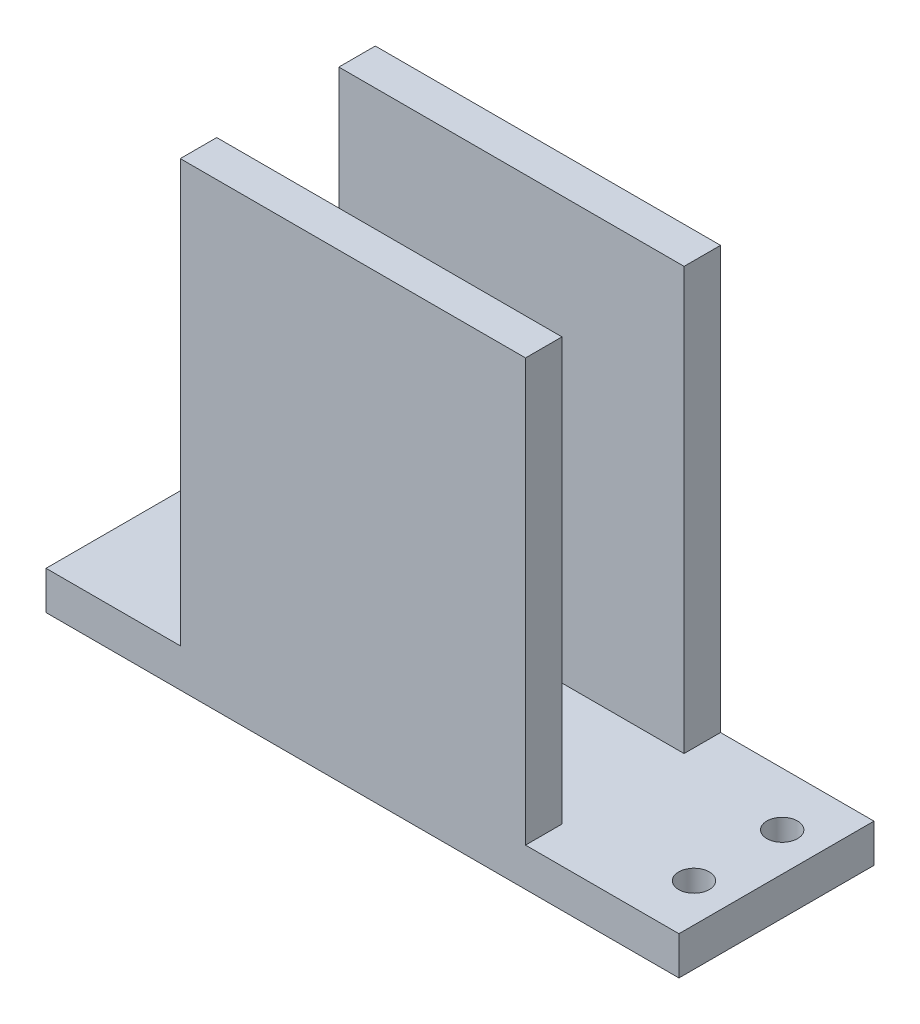
from build123d import *

# Parameters (mm, degrees)
SKETCH1_W           = 165
SKETCH1_H           = 50.84
BOSS_EXTRUDE1_DEPTH = 10
SKETCH2_W           = 90
SKETCH2_H           = 10
BOSS_EXTRUDE2_DEPTH = 110
SKETCH3_R           = 4
CUT_EXTRUDE1_DEPTH  = 30
SKETCH4_W           = 90
SKETCH4_H           = 110
CUT_EXTRUDE2_DEPTH  = 0.5


with BuildPart() as part:
    # Sketch1 → Boss-Extrude1 (new body)
    with BuildSketch(Plane(origin=(0, 0, 0), x_dir=(1, 0, 0), z_dir=(0, 1, 0))):
        with Locations((82.5, 25.42)):
            Rectangle(SKETCH1_W, SKETCH1_H)
    extrude(amount=BOSS_EXTRUDE1_DEPTH)

    # Sketch2 → Boss-Extrude2 (add)
    with BuildSketch(Plane(origin=(0, 10, 0), x_dir=(1, 0, 0), z_dir=(0, 1, 0))):
        with Locations((80, 45.84)):
            Rectangle(SKETCH2_W, SKETCH2_H)
        with Locations((80, 5)):
            Rectangle(SKETCH2_W, SKETCH2_H)
    extrude(amount=BOSS_EXTRUDE2_DEPTH)

    # Sketch3 → Cut-Extrude1 (cut)
    with BuildSketch(Plane(origin=(0, 10, 0), x_dir=(1, 0, 0), z_dir=(0, 1, 0))):
        with Locations((30, 36.92)):
            Circle(SKETCH3_R)
        with Locations((155, 36.92)):
            Circle(SKETCH3_R)
    cut_extrude1 = extrude(amount=-CUT_EXTRUDE1_DEPTH, mode=Mode.SUBTRACT)

    # Mirror1: Cut-Extrude1 across plane
    add(cut_extrude1.mirror(Plane(origin=(0, 0, -25.42), x_dir=(1, 0, 0), z_dir=(0, 0, -1))), mode=Mode.SUBTRACT)

    # Sketch4 → Cut-Extrude2 (cut)
    with BuildSketch(Plane(origin=(0, 0, -10), x_dir=(-1, 0, 0), z_dir=(0, 0, -1))):
        with Locations((-80, 65)):
            Rectangle(SKETCH4_W, SKETCH4_H)
    cut_extrude2 = extrude(amount=-CUT_EXTRUDE2_DEPTH, mode=Mode.SUBTRACT)

    # Mirror2: Cut-Extrude2 across plane
    add(cut_extrude2.mirror(Plane(origin=(0, 0, -25.42), x_dir=(1, 0, 0), z_dir=(0, 0, -1))), mode=Mode.SUBTRACT)


solid = part.part
